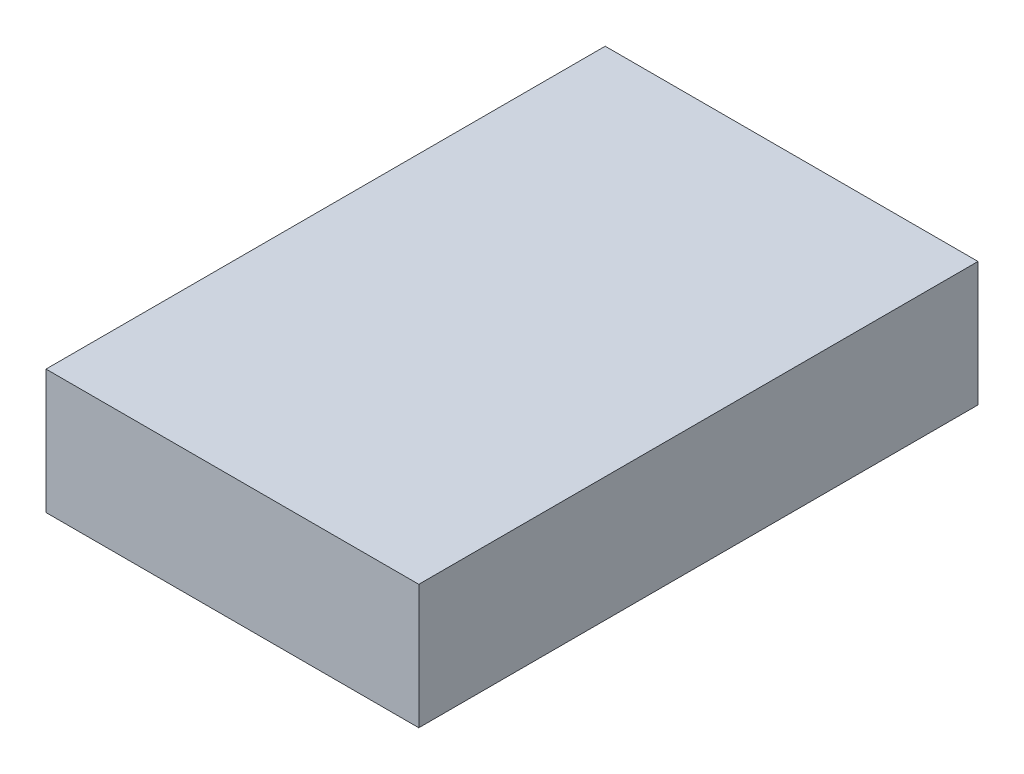
from build123d import *

# Parameters (mm, degrees)
SKETCH1_W           = 609.6
SKETCH1_H           = 914.4
BOSS_EXTRUDE1_DEPTH = 203.2


with BuildPart() as part:
    # Sketch1 → Boss-Extrude1 (new body)
    with BuildSketch(Plane(origin=(0, 0, 0), x_dir=(1, 0, 0), z_dir=(0, 1, 0))):
        with Locations((304.8, 457.2)):
            Rectangle(SKETCH1_W, SKETCH1_H)
    extrude(amount=BOSS_EXTRUDE1_DEPTH)


solid = part.part
